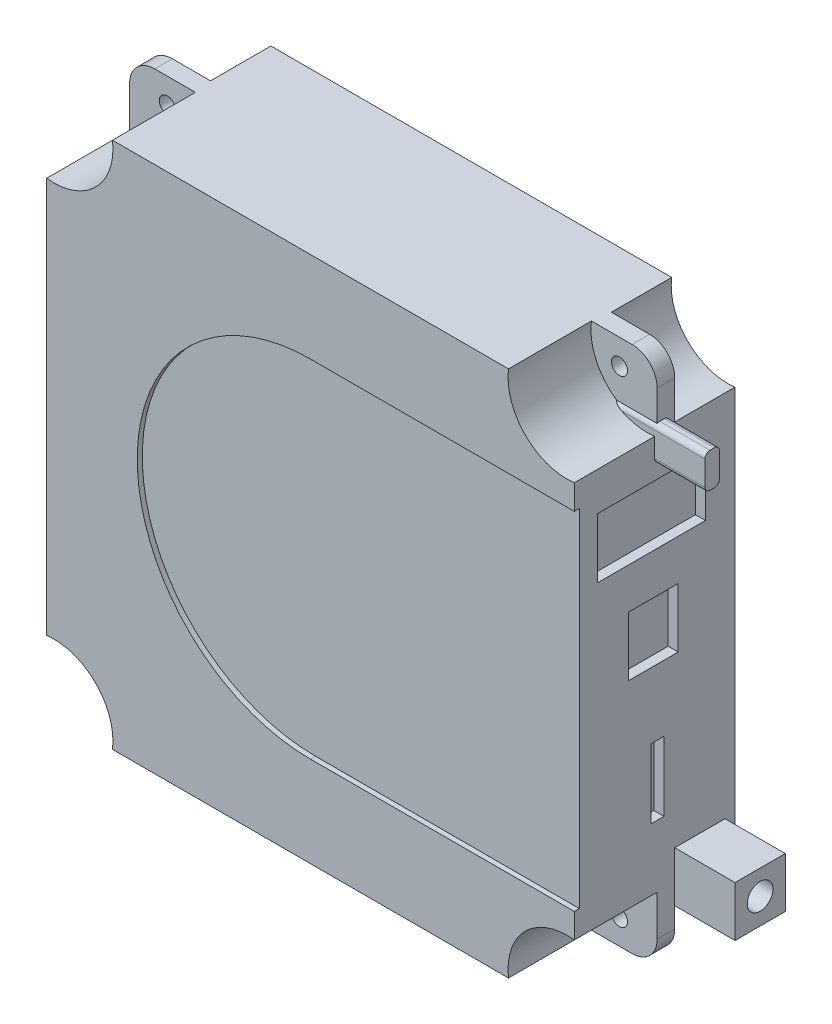
from build123d import *

# Parameters (mm, degrees)
SKETCH_1_R          = 1.6
EXTRUDE_1_DEPTH     = 32
SKETCH_2_W          = 9.930433433
SKETCH_2_H          = 11.817215785
SKETCH_2_W_2        = 21.449736214
SKETCH_2_H_2        = 11.916520119
SKETCH_2_W_3        = 2.581912693
SKETCH_2_H_3        = 13.803302471
CUT_EXTRUDE_1_DEPTH = 2
SKETCH_3_R          = 11.717000941
CUT_EXTRUDE_2_DEPTH = 16.5
SKETCH_4_R          = 11.241694858
CUT_EXTRUDE_3_DEPTH = 12
SKETCH_5_R          = 34.479667549
CUT_EXTRUDE_4_DEPTH = 1
EXTRUDE_START       = -13
SKETCH_7_W          = 10
SKETCH_7_H          = 10
EXTRUDE_2_DEPTH     = 25
SKETCH_8_R          = 2.56518407
CUT_EXTRUDE_5_DEPTH = 5
EXTRUDE_3_DEPTH     = 10


with BuildPart() as part:
    # 草图1 → 凸台-拉伸1 (new body)
    with BuildSketch(Plane.XY):
        with BuildLine():
            Line((-47.5, -52.5), (47.5, -52.5))
            ThreePointArc((47.5, -52.5), (51.035533906, -51.035533906), (52.5, -47.5))
            Line((52.5, -47.5), (52.5, 47.5))
            ThreePointArc((52.5, 47.5), (51.035533906, 51.035533906), (47.5, 52.5))
            Line((47.5, 52.5), (-47.5, 52.5))
            ThreePointArc((-47.5, 52.5), (-51.035533906, 51.035533906), (-52.5, 47.5))
            Line((-52.5, 47.5), (-52.5, -47.5))
            ThreePointArc((-52.5, -47.5), (-51.035533906, -51.035533906), (-47.5, -52.5))
        make_face()
        with Locations((-45, 47.5)):
            Circle(SKETCH_1_R, mode=Mode.SUBTRACT)
        with Locations((45, 47.5)):
            Circle(SKETCH_1_R, mode=Mode.SUBTRACT)
        with Locations((-45, -47.5)):
            Circle(SKETCH_1_R, mode=Mode.SUBTRACT)
        with Locations((45, -47.5)):
            Circle(SKETCH_1_R, mode=Mode.SUBTRACT)
    extrude(amount=EXTRUDE_1_DEPTH)

    # 草图2 → 切除-拉伸1 (cut)
    with BuildSketch(Plane(origin=(52.5, 0, 0), x_dir=(0, 0, -1), z_dir=(1, 0, 0))):
        with Locations((-16.268668235, 5.797602345)):
            Rectangle(SKETCH_2_W, SKETCH_2_H)
        with Locations((-16.612129338, 25.805351216)):
            Rectangle(SKETCH_2_W_2, SKETCH_2_H_2)
        with Locations((-15.435990978, -20.113761829)):
            Rectangle(SKETCH_2_W_3, SKETCH_2_H_3)
    extrude(amount=-CUT_EXTRUDE_1_DEPTH, mode=Mode.SUBTRACT)

    # 草图3 → 切除-拉伸2 (cut)
    with BuildSketch(Plane.XY.offset(32)):
        with Locations((-51.035533906, 51.035533906)):
            Circle(SKETCH_3_R)
        with Locations((51.035533906, 51.035533906)):
            Circle(SKETCH_3_R)
        with Locations((51.035533906, -51.035533906)):
            Circle(SKETCH_3_R)
        with Locations((-51.035533906, -51.035533906)):
            Circle(SKETCH_3_R)
    extrude(amount=-CUT_EXTRUDE_2_DEPTH, mode=Mode.SUBTRACT)

    # 草图4 → 切除-拉伸3 (cut)
    with BuildSketch(Plane(origin=(0, 0, 0), x_dir=(-1, 0, 0), z_dir=(0, 0, -1))):
        with Locations((-51.035533906, 51.035533906)):
            Circle(SKETCH_4_R)
        with Locations((51.035533906, 51.035533906)):
            Circle(SKETCH_4_R)
        with Locations((51.035533906, -51.035533906)):
            Circle(SKETCH_4_R)
        with Locations((-51.035533906, -51.035533906)):
            Circle(SKETCH_4_R)
    extrude(amount=-CUT_EXTRUDE_3_DEPTH, mode=Mode.SUBTRACT)

    # 草图5 → 切除-拉伸4 (cut)
    with BuildSketch(Plane.XY.offset(32)):
        Circle(SKETCH_5_R)
        with BuildLine():
            Line((52.5, 34.479667549), (0, 34.479667549))
            ThreePointArc((0, 34.479667549), (24.380806737, 24.380806737), (34.479667549, 0))
            ThreePointArc((34.479667549, 0), (24.380806737, -24.380806737), (0, -34.479667549))
            Line((0, -34.479667549), (52.5, -34.479667549))
            Line((52.5, -34.479667549), (52.5, 34.479667549))
        make_face()
    extrude(amount=-CUT_EXTRUDE_4_DEPTH, mode=Mode.SUBTRACT)

    # 草图7 → 凸台-拉伸2 (add)
    with BuildSketch(Plane(origin=(52.5, 0, 0), x_dir=(0, 0, -1), z_dir=(1, 0, 0)).offset(EXTRUDE_START)):
        with Locations((-7, -38.5)):
            Rectangle(SKETCH_7_W, SKETCH_7_H)
    extrude(amount=EXTRUDE_2_DEPTH)

    # 草图8 → 切除-拉伸5 (cut)
    with BuildSketch(Plane(origin=(64.5, 0, 0), x_dir=(0, 0, -1), z_dir=(1, 0, 0))):
        with Locations((-7, -38.381125217)):
            Circle(SKETCH_8_R)
    extrude(amount=-CUT_EXTRUDE_5_DEPTH, mode=Mode.SUBTRACT)

    # 草图9 → 凸台-拉伸3 (add, symmetric)
    with BuildSketch(Plane(origin=(52.5, 0, 0), x_dir=(0, 0, -1), z_dir=(1, 0, 0))):
        with BuildLine():
            Line((-15, 41.5), (-14.108172131, 41.5))
            ThreePointArc((-14.108172131, 41.5), (-13.40106535, 41.207106781), (-13.108172131, 40.5))
            Line((-13.108172131, 40.5), (-13.108172131, 35.607560513))
            ThreePointArc((-13.108172131, 35.607560513), (-13.40106535, 34.900453732), (-14.108172131, 34.607560513))
            Line((-14.108172131, 34.607560513), (-15, 34.607560513))
            ThreePointArc((-15, 34.607560513), (-15.707106781, 34.900453732), (-16, 35.607560513))
            Line((-16, 35.607560513), (-16, 40.5))
            ThreePointArc((-16, 40.5), (-15.707106781, 41.207106781), (-15, 41.5))
        make_face()
    extrude(amount=EXTRUDE_3_DEPTH, both=True)


solid = part.part
